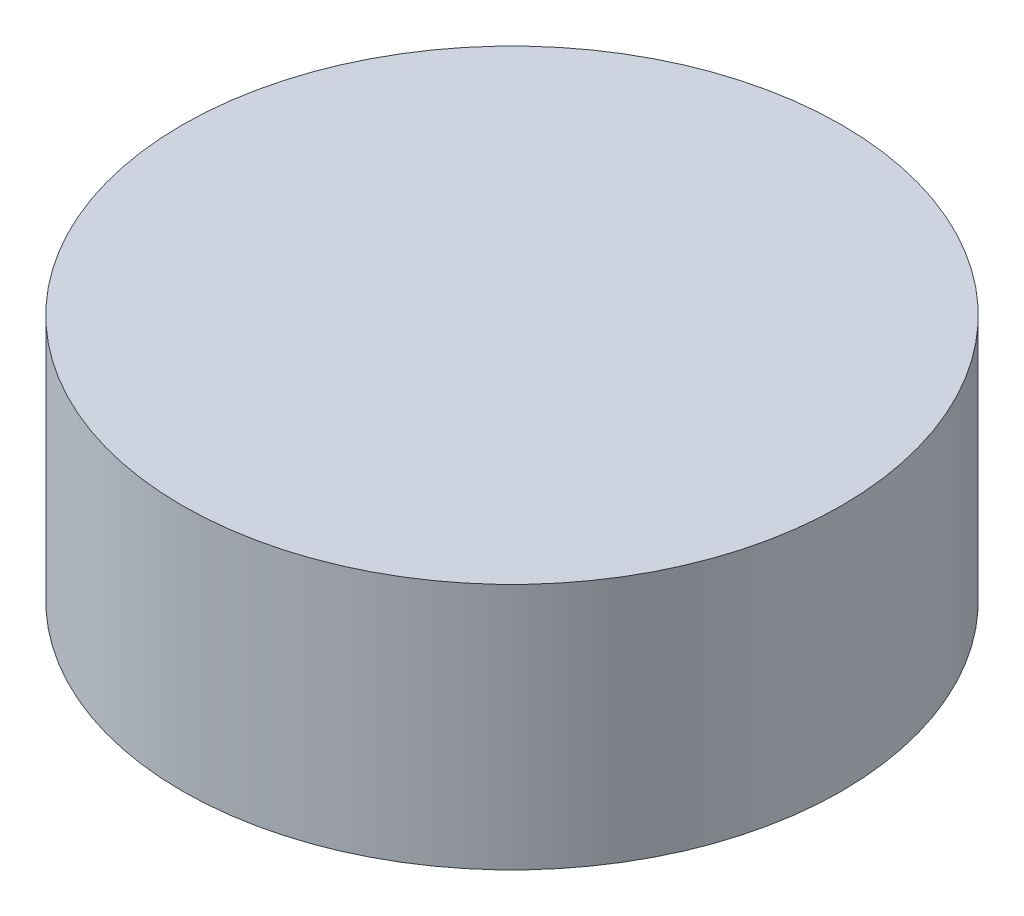
from build123d import *

# Parameters (mm, degrees)
SKETCH1_R           = 4
BOSS_EXTRUDE1_DEPTH = 3


with BuildPart() as part:
    # Sketch1 → Boss-Extrude1 (new body)
    with BuildSketch(Plane(origin=(0, 0, 0), x_dir=(1, 0, 0), z_dir=(0, 1, 0))):
        Circle(SKETCH1_R)
    extrude(amount=-BOSS_EXTRUDE1_DEPTH)


solid = part.part
